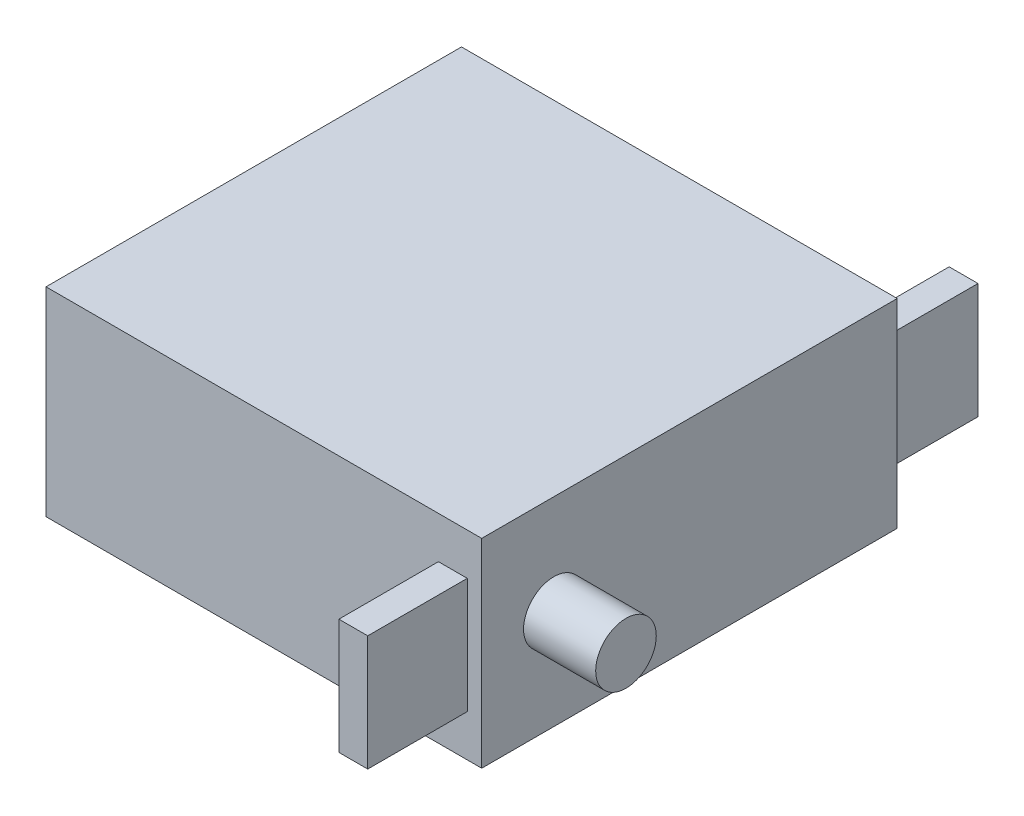
from build123d import *

# Parameters (mm, degrees)
SKETCH1_W           = 30.2
SKETCH1_H           = 28.8
BOSS_EXTRUDE1_DEPTH = 6.9
SKETCH2_R           = 2.1
BOSS_EXTRUDE2_DEPTH = 5
SKETCH3_W           = 2
SKETCH3_H           = 8
BOSS_EXTRUDE3_DEPTH = 6.9
SKETCH4_W           = 2
SKETCH4_H           = 8
BOSS_EXTRUDE4_DEPTH = 6.6


with BuildPart() as part:
    # Sketch1 → Boss-Extrude1 (new body, symmetric)
    with BuildSketch(Plane(origin=(0, 0, 0), x_dir=(1, 0, 0), z_dir=(0, 1, 0))):
        with Locations((15.1, 14.4)):
            Rectangle(SKETCH1_W, SKETCH1_H)
    extrude(amount=BOSS_EXTRUDE1_DEPTH, both=True)

    # Sketch2 → Boss-Extrude2 (add)
    with BuildSketch(Plane(origin=(30.2, 0, 0), x_dir=(0, 0, -1), z_dir=(1, 0, 0))):
        with Locations((5, 0)):
            Circle(SKETCH2_R)
    extrude(amount=BOSS_EXTRUDE2_DEPTH)

    # Sketch3 → Boss-Extrude3 (add)
    with BuildSketch(Plane.XY):
        with Locations((28.2, 0)):
            Rectangle(SKETCH3_W, SKETCH3_H)
    extrude(amount=BOSS_EXTRUDE3_DEPTH)

    # Sketch4 → Boss-Extrude4 (add)
    with BuildSketch(Plane(origin=(0, 0, -28.8), x_dir=(-1, 0, 0), z_dir=(0, 0, -1))):
        with Locations((-28.2, 0)):
            Rectangle(SKETCH4_W, SKETCH4_H)
    extrude(amount=BOSS_EXTRUDE4_DEPTH)


solid = part.part
